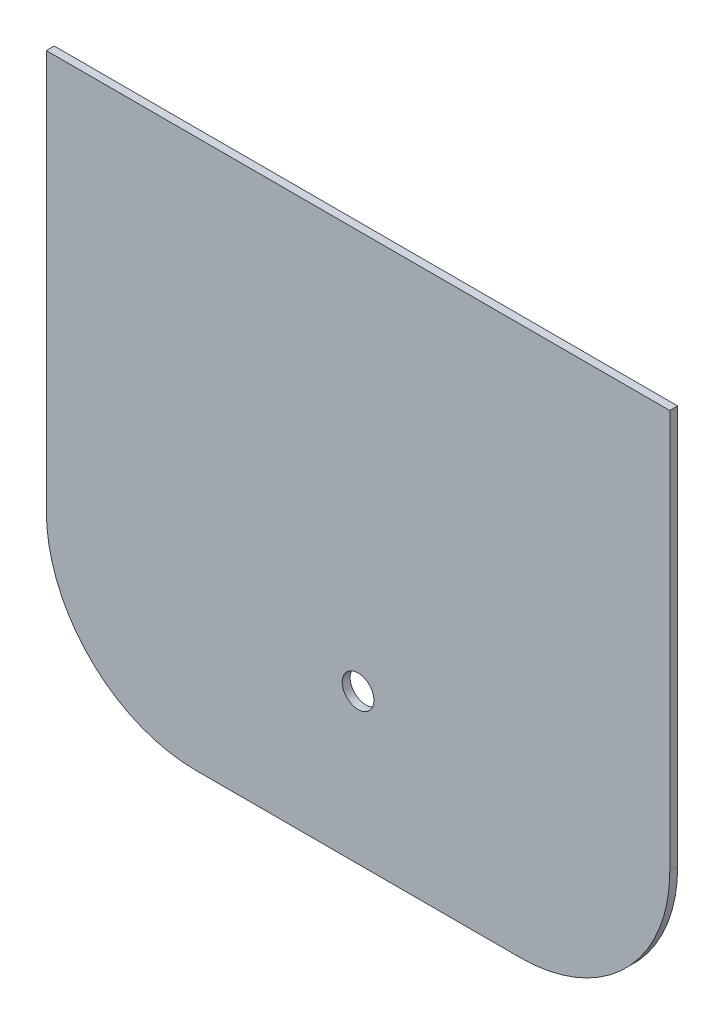
from build123d import *

# Parameters (mm, degrees)
CROQUIS1_W              = 250
CROQUIS1_H              = 220
SALIENTE_EXTRUIR1_DEPTH = 3.175
REDONDEO1_R             = 60
CROQUIS2_R              = 6.35
CORTAR_EXTRUIR1_DEPTH   = 6.35


with BuildPart() as part:
    # Croquis1 → Saliente-Extruir1 (new body)
    with BuildSketch(Plane.XY):
        with Locations((125, 110)):
            Rectangle(CROQUIS1_W, CROQUIS1_H)
    extrude(amount=SALIENTE_EXTRUIR1_DEPTH)

    # Redondeo1
    redondeo1_edges = [part.edges().sort_by_distance(p)[0] for p in [
        (250, 0, 1.5875),
        (0, 0, 1.5875),
    ]]
    fillet(redondeo1_edges, radius=REDONDEO1_R)

    # Croquis2 → Cortar-Extruir1 (cut)
    with BuildSketch(Plane.XY.offset(3.175)):
        with Locations((125, 60)):
            Circle(CROQUIS2_R)
    extrude(amount=-CORTAR_EXTRUIR1_DEPTH, mode=Mode.SUBTRACT)


solid = part.part
